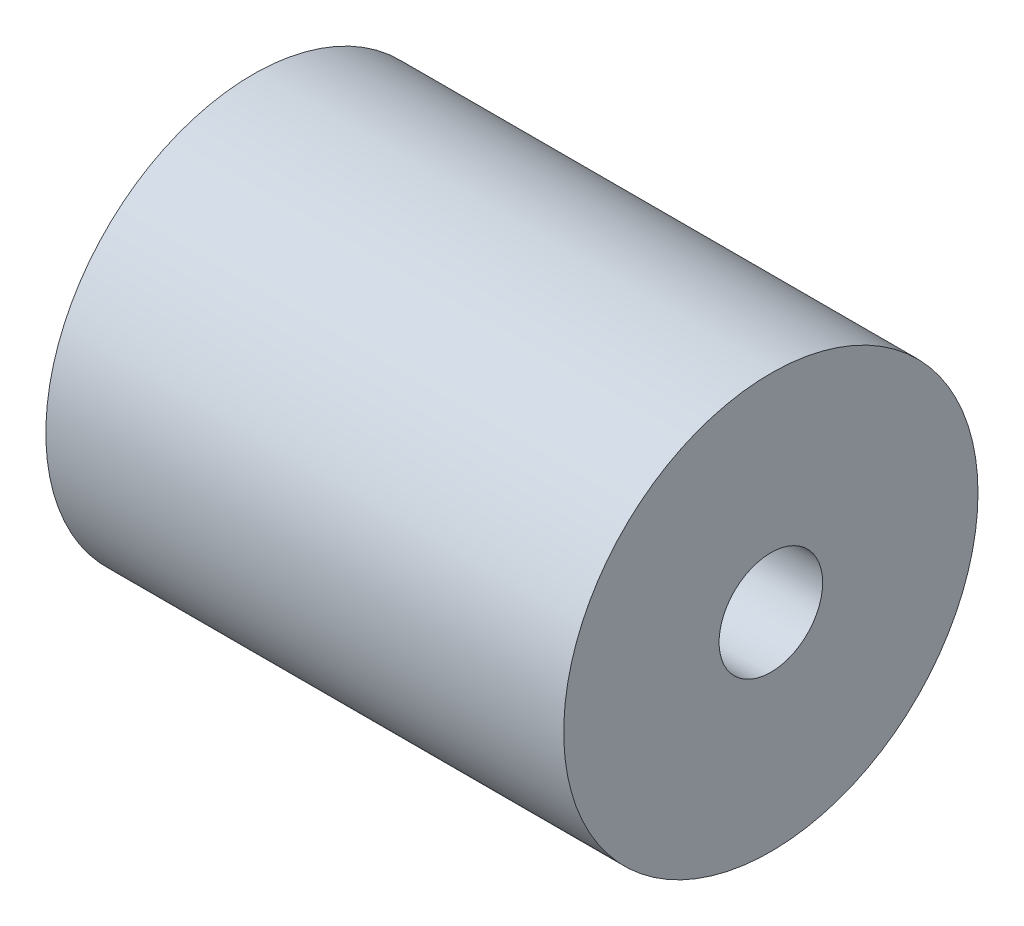
from build123d import *

# Parameters (mm, degrees)
BOSS_EXTRUDE1_DEPTH      = 17.5
BOSS_EXTRUDE1_DEPTH_BACK = 7.5
SKETCH1_R                = 10
SKETCH1_R_2              = 2.5


with BuildPart() as part:
    # Sketch1 → Boss-Extrude1 (new, two sides: drawn at the far end of the back side and taken through both)
    with BuildSketch(Plane(origin=(0, 0, 0), x_dir=(0, 0, -1), z_dir=(1, 0, 0)).offset(-BOSS_EXTRUDE1_DEPTH_BACK)):
        Circle(SKETCH1_R)
        Circle(SKETCH1_R_2, mode=Mode.SUBTRACT)
    extrude(amount=BOSS_EXTRUDE1_DEPTH + BOSS_EXTRUDE1_DEPTH_BACK)


solid = part.part
